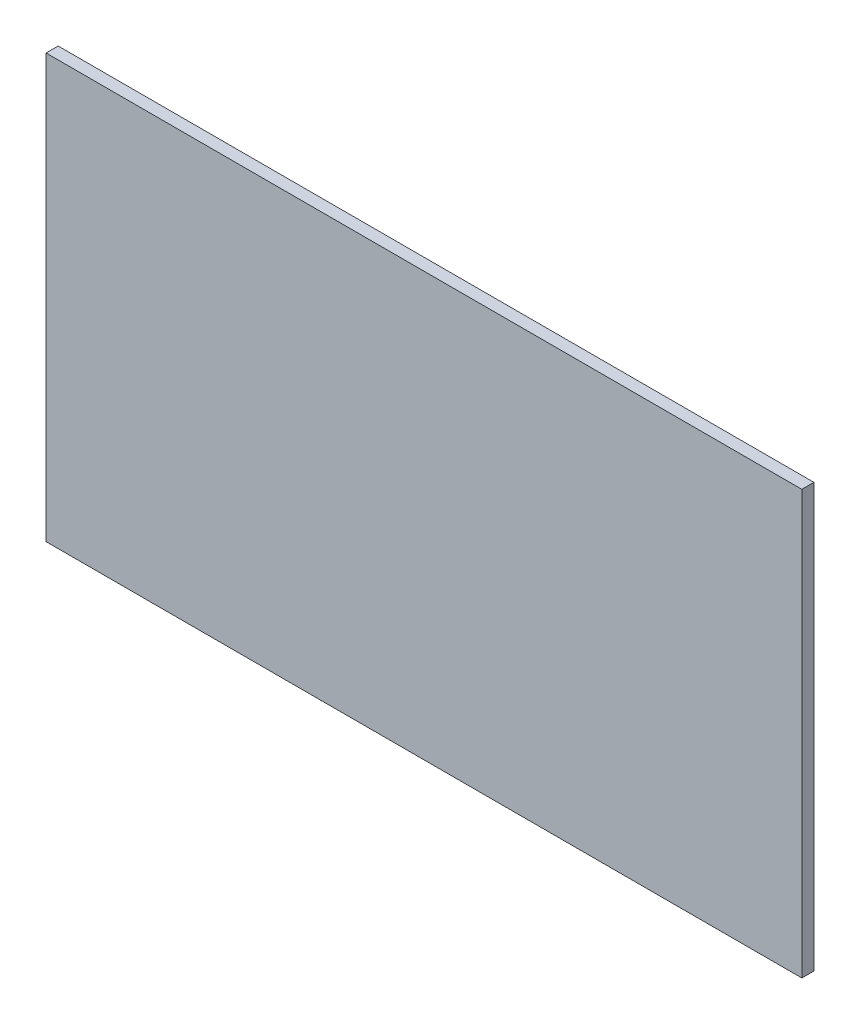
from build123d import *

# Parameters (mm, degrees)
SKETCH_1_W      = 250
SKETCH_1_H      = 140
EXTRUDE_1_DEPTH = 4


with BuildPart() as part:
    # 草图1 → 凸台-拉伸1 (new body)
    with BuildSketch(Plane.XY):
        with Locations((62.770298772, -25.749592398)):
            Rectangle(SKETCH_1_W, SKETCH_1_H)
    extrude(amount=EXTRUDE_1_DEPTH)


solid = part.part
